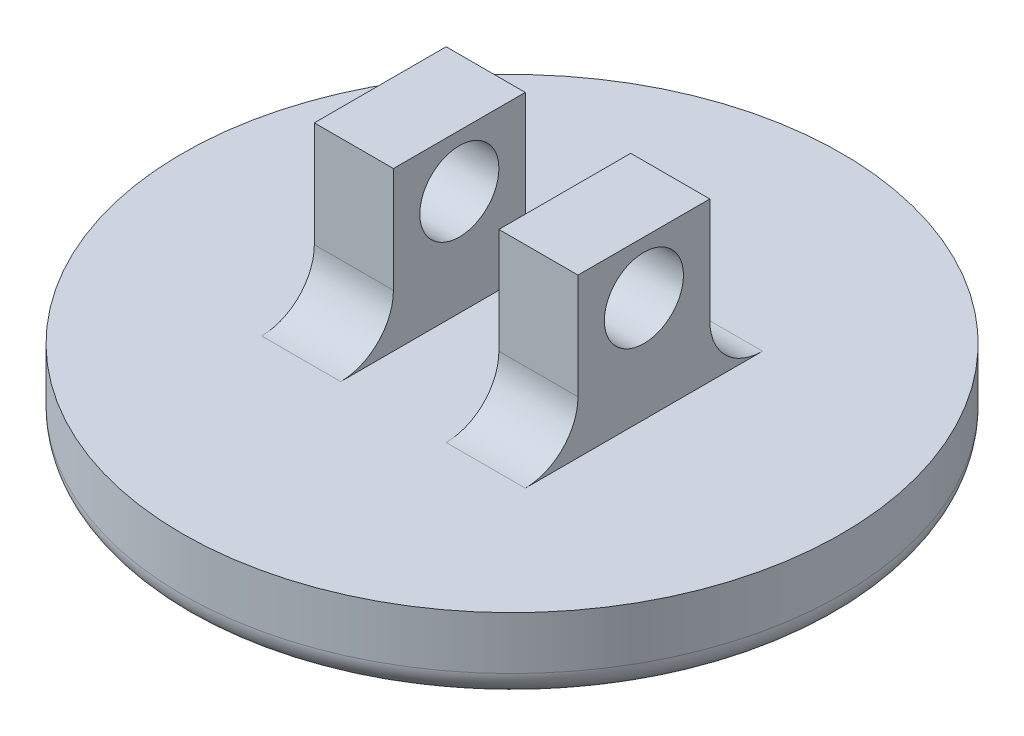
from build123d import *

# Parameters (mm, degrees)
SKETCH1_R               = 12.5
BOSS_EXTRUDE1_DEPTH     = 3
SKETCH2_W               = 3
SKETCH2_H               = 5
BOSS_EXTRUDE2_DEPTH     = 6
SKETCH3_R               = 1.5
CUT_EXTRUDE1_DEPTH      = 8.5
CUT_EXTRUDE1_DEPTH_BACK = 18.5
FILLET1_R               = 2
FILLET2_R               = 1


with BuildPart() as part:
    # Sketch1 → Boss-Extrude1 (new body)
    with BuildSketch(Plane(origin=(0, 0, 0), x_dir=(1, 0, 0), z_dir=(0, 1, 0))):
        with Locations(Location((0, 0, 0), (0, 0, 270))):  # turned: the seam where the file's is
            Circle(SKETCH1_R)
    extrude(amount=BOSS_EXTRUDE1_DEPTH)

    # Sketch2 → Boss-Extrude2 (add)
    with BuildSketch(Plane(origin=(0, 3, 0), x_dir=(1, 0, 0), z_dir=(0, 1, 0))):
        with Locations((-3.5, 0)):
            Rectangle(SKETCH2_W, SKETCH2_H)
        with Locations((3.5, 0)):
            Rectangle(SKETCH2_W, SKETCH2_H)
    extrude(amount=BOSS_EXTRUDE2_DEPTH)

    # Sketch3 → Cut-Extrude1 (cut, two sides)
    with BuildSketch(Plane(origin=(5, 0, 0), x_dir=(0, 0, -1), z_dir=(1, 0, 0))) as cut_extrude1_sk:
        with Locations((0, 7)):
            Circle(SKETCH3_R)
    extrude(amount=CUT_EXTRUDE1_DEPTH, mode=Mode.SUBTRACT)
    extrude(cut_extrude1_sk.sketch, amount=-CUT_EXTRUDE1_DEPTH_BACK, mode=Mode.SUBTRACT)

    # Fillet1
    fillet1_edges = [part.edges().sort_by_distance(p)[0] for p in [
        (3.5, 3, -2.5),
        (3.5, 3, 2.5),
        (-3.5, 3, -2.5),
        (-3.5, 3, 2.5),
    ]]
    fillet(fillet1_edges, radius=FILLET1_R)

    # Fillet2
    fillet2_edges = [part.edges().sort_by_distance(p)[0] for p in [
        (0, 0, -12.5),
    ]]
    fillet(fillet2_edges, radius=FILLET2_R)


solid = part.part
